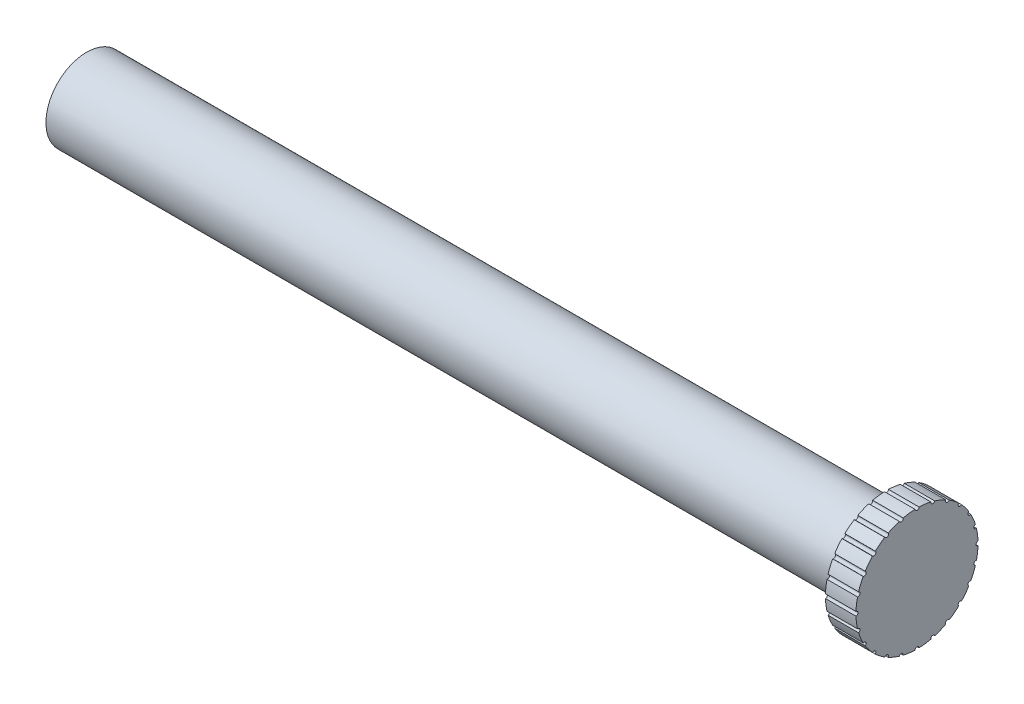
from build123d import *

# Parameters (mm, degrees)
SKETCH1_R           = 4
BOSS_EXTRUDE2_DEPTH = 78.63
SKETCH2_R           = 6
BOSS_EXTRUDE3_DEPTH = 3
SKETCH3_R           = 0.2
CUT_EXTRUDE1_DEPTH  = 3
CIRPATTERN1_COUNT   = 24


with BuildPart() as part:
    # Sketch1 → Boss-Extrude2 (new body)
    with BuildSketch(Plane(origin=(0, 0, 0), x_dir=(0, 0, -1), z_dir=(1, 0, 0))):
        Circle(SKETCH1_R)
    extrude(amount=BOSS_EXTRUDE2_DEPTH)

    # Sketch2 → Boss-Extrude3 (add)
    with BuildSketch(Plane(origin=(78.63, 0, 0), x_dir=(0, 0, -1), z_dir=(1, 0, 0))):
        Circle(SKETCH2_R)
    extrude(amount=BOSS_EXTRUDE3_DEPTH)

    # Sketch3 → Cut-Extrude1 (cut)
    with BuildSketch(Plane(origin=(81.63, 0, 0), x_dir=(0, 0, -1), z_dir=(1, 0, 0))):
        with Locations((-6, 0)):
            Circle(SKETCH3_R)
    cut_extrude1 = extrude(amount=-CUT_EXTRUDE1_DEPTH, mode=Mode.SUBTRACT)

    # CirPattern1: Cut-Extrude1 ×24 about axis
    cirpattern1_axis = Axis((0, 0, -0.003264402), (1, 0, 0))
    for i in range(1, CIRPATTERN1_COUNT):
        add(cut_extrude1.rotate(cirpattern1_axis, i * 360 / CIRPATTERN1_COUNT), mode=Mode.SUBTRACT)


solid = part.part
